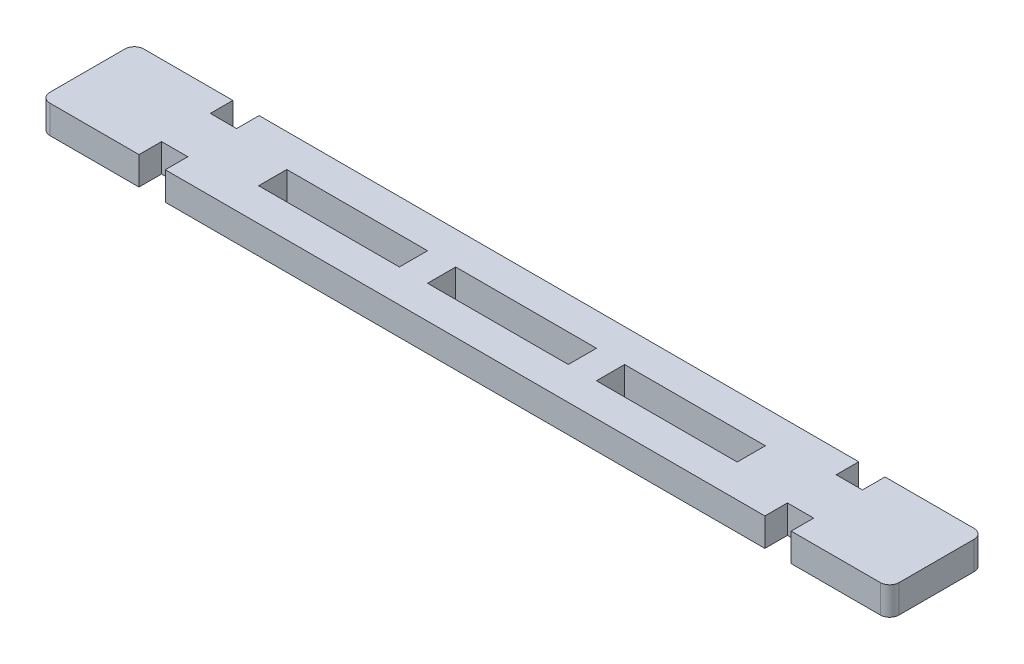
from build123d import *

# Parameters (mm, degrees)
SKETCH1_W                                = 181
SKETCH1_H                                = 20
BOSS_EXTRUDE1_DEPTH                      = 6
SKETCH3_W                                = 30
SKETCH3_H                                = 6
CUT_EXTRUDE1_DEPTH                       = 7
SKETCH4_W                                = 6
SKETCH4_H                                = 5
CUT_EXTRUDE2_DEPTH                       = 7
FILLET1_R                                = 2
BOSS_EXTRUDE2_DEPTH                      = 6
MIRROR2_AT_THE_SECOND_PLANE_COPY_1_DEPTH = 6


with BuildPart() as part:
    # Sketch1 → Boss-Extrude1 (new body)
    with BuildSketch(Plane(origin=(0, 0, 0), x_dir=(1, 0, 0), z_dir=(0, 1, 0))):
        Rectangle(SKETCH1_W, SKETCH1_H)
    extrude(amount=BOSS_EXTRUDE1_DEPTH)

    # Sketch3 → Cut-Extrude1 (cut, through all)
    with BuildSketch(Plane(origin=(0, 6, 0), x_dir=(1, 0, 0), z_dir=(0, 1, 0))):
        with Locations((36, 0)):
            Rectangle(SKETCH3_W, SKETCH3_H)
        Rectangle(SKETCH3_W, SKETCH3_H)
        with Locations((-36, 0)):
            Rectangle(SKETCH3_W, SKETCH3_H)
    extrude(amount=-CUT_EXTRUDE1_DEPTH, mode=Mode.SUBTRACT)

    # Sketch4 → Cut-Extrude2 (cut, through all)
    with BuildSketch(Plane.XZ):
        with Locations((-66.7, 7.5)):
            Rectangle(SKETCH4_W, SKETCH4_H)
        with Locations((-66.7, -7.5)):
            Rectangle(SKETCH4_W, SKETCH4_H)
    cut_extrude2 = extrude(amount=-CUT_EXTRUDE2_DEPTH, mode=Mode.SUBTRACT)

    # Mirror1: Cut-Extrude2 across plane
    add(cut_extrude2.mirror(Plane(origin=(0, 0, 0), x_dir=(0, 0, 1), z_dir=(1, 0, 0))), mode=Mode.SUBTRACT)

    # Fillet1
    fillet1_edges = [part.edges().sort_by_distance(p)[0] for p in [
        (-90.5, 3, -10),
        (-90.5, 3, 10),
        (90.5, 3, 10),
        (90.5, 3, -10),
    ]]
    fillet(fillet1_edges, radius=FILLET1_R)

    # Sketch5 → Boss-Extrude2 (add)
    with BuildSketch(Plane(origin=(0, 6, 0), x_dir=(1, 0, 0), z_dir=(0, 1, 0))):
        Polygon((-69.5, 5.2), (-69.5, 9.8), (-69.5, 10), (-69.7, 10), (-69.7, 5), (-63.7, 5), (-63.7, 10), (-63.9, 10), (-63.9, 9.8), (-63.9, 5.2), align=None)
    boss_extrude2 = extrude(amount=-BOSS_EXTRUDE2_DEPTH)

    # Mirror2: Boss-Extrude2 across plane
    add(boss_extrude2.mirror(Plane(origin=(0, 0, 0), x_dir=(0, 0, 1), z_dir=(1, 0, 0))))

    # Mirror2 at the second plane: Boss-Extrude2 across plane
    add(boss_extrude2.mirror(Plane.XY))

    # Mirror2 at the second plane copy 1 sketc → Mirror2 at the second plane copy 1 (add)
    with BuildSketch(Plane(origin=(0, 6, 0), x_dir=(-1, 0, 0), z_dir=(0, 1, 0))):
        Polygon((-69.5, 5.2), (-69.5, 9.8), (-69.5, 10), (-69.7, 10), (-69.7, 5), (-63.7, 5), (-63.7, 10), (-63.9, 10), (-63.9, 9.8), (-63.9, 5.2), align=None)
    extrude(amount=-MIRROR2_AT_THE_SECOND_PLANE_COPY_1_DEPTH)


solid = part.part
